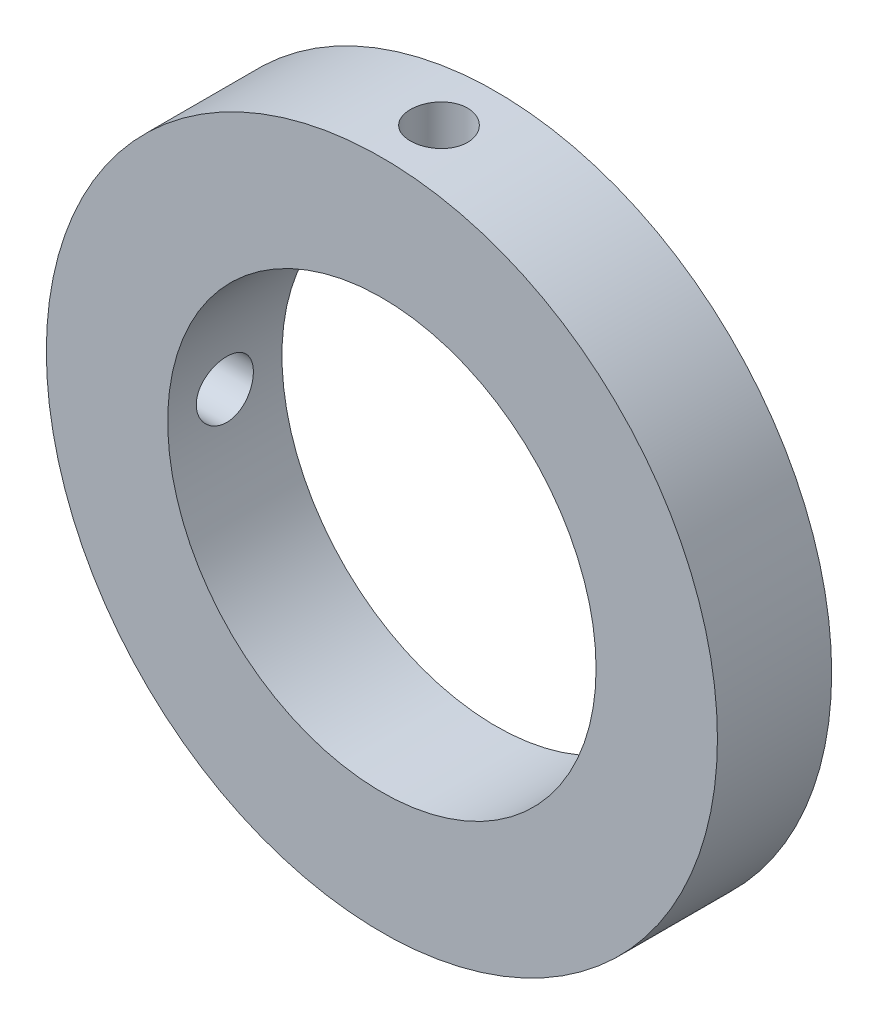
from build123d import *

# Parameters (mm, degrees)
SKETCH1_R           = 23.5
SKETCH1_R_2         = 15
BOSS_EXTRUDE1_DEPTH = 8
CUT_EXTRUDE1_START  = -8.633931
SKETCH3_R           = 2
CUT_EXTRUDE1_DEPTH  = 8.633931
CIRPATTERN1_COUNT   = 2
CIRPATTERN1_ANGLE   = 90


with BuildPart() as part:
    # Sketch1 → Boss-Extrude1 (new body)
    with BuildSketch(Plane.XY):
        Circle(SKETCH1_R)
        Circle(SKETCH1_R_2, mode=Mode.SUBTRACT)
    extrude(amount=BOSS_EXTRUDE1_DEPTH)

    # Sketch3 → Cut-Extrude1 (cut)
    with BuildSketch(Plane(origin=(0, 23.5, 8), x_dir=(1, 0, 0), z_dir=(0, 1, 0)).offset(CUT_EXTRUDE1_START)):
        with Locations((0, 4)):
            Circle(SKETCH3_R)
    cut_extrude1 = extrude(amount=CUT_EXTRUDE1_DEPTH, mode=Mode.SUBTRACT)

    # CirPattern1: Cut-Extrude1 ×2 about axis
    cirpattern1_axis = Axis((0, 0, 8), (0, 0, 1))
    for i in range(1, CIRPATTERN1_COUNT):
        add(cut_extrude1.rotate(cirpattern1_axis, i * CIRPATTERN1_ANGLE / (CIRPATTERN1_COUNT - 1)), mode=Mode.SUBTRACT)


solid = part.part
